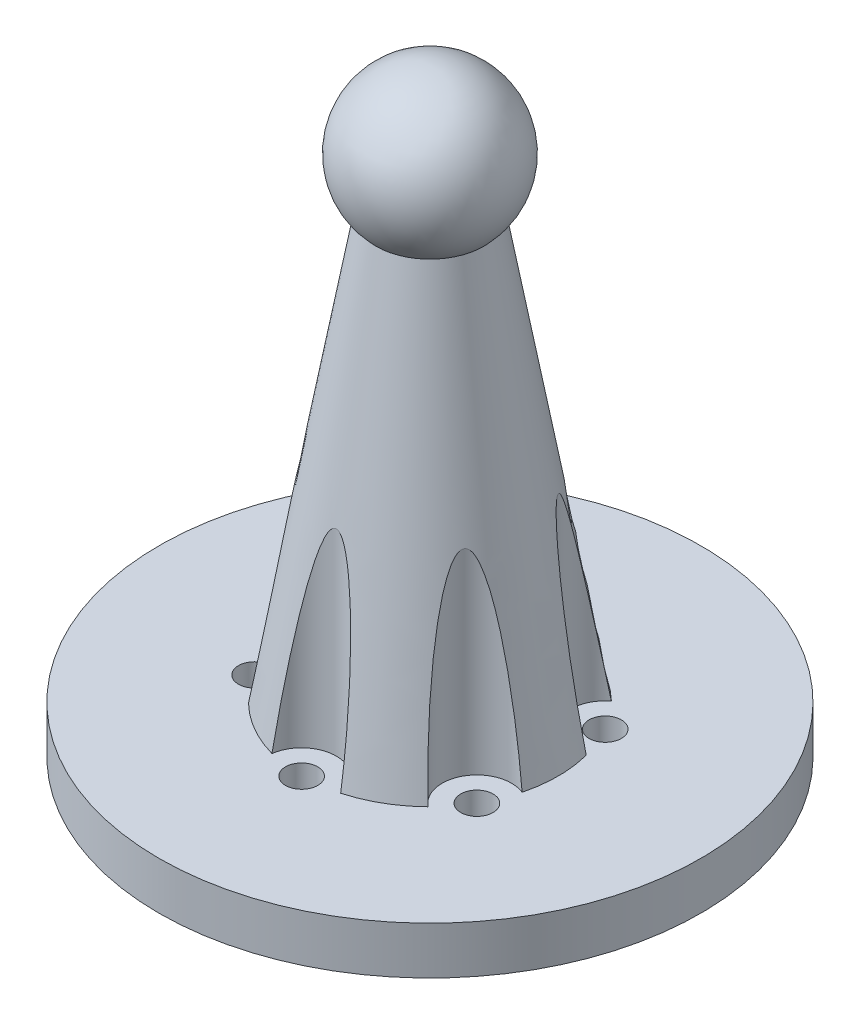
from build123d import *

# Parameters (mm, degrees)
SKETCH_1_R          = 28.5
SKETCH_1_R_2        = 1.7
EXTRUDE_1_DEPTH     = 5
SKETCH_2_R          = 13.5
EXTRUDE_2_DEPTH     = 50
EXTRUDE_2_TAPER     = 10
SKETCH_3_R          = 3.65
CUT_EXTRUDE_1_DEPTH = 50


with BuildPart() as part:
    # 草图1 → 凸台-拉伸1 (new body)
    with BuildSketch(Plane(origin=(0, 0, 0), x_dir=(1, 0, 0), z_dir=(0, 1, 0))):
        Circle(SKETCH_1_R)
        with Locations((0, 13.5)):
            Circle(SKETCH_1_R_2, mode=Mode.SUBTRACT)
        with Locations((11.691342951, 6.75)):
            Circle(SKETCH_1_R_2, mode=Mode.SUBTRACT)
        with Locations((11.691342951, -6.75)):
            Circle(SKETCH_1_R_2, mode=Mode.SUBTRACT)
        with Locations((0, -13.5)):
            Circle(SKETCH_1_R_2, mode=Mode.SUBTRACT)
        with Locations((-11.691342951, -6.75)):
            Circle(SKETCH_1_R_2, mode=Mode.SUBTRACT)
        with Locations((-11.691342951, 6.75)):
            Circle(SKETCH_1_R_2, mode=Mode.SUBTRACT)
    extrude(amount=EXTRUDE_1_DEPTH)

    # 草图2 → 凸台-拉伸2 (add)
    with BuildSketch(Plane(origin=(0, 5, 0), x_dir=(1, 0, 0), z_dir=(0, 1, 0))):
        Circle(SKETCH_2_R)
    extrude(amount=EXTRUDE_2_DEPTH, taper=EXTRUDE_2_TAPER)

    # 草图3 → 切除-拉伸1 (cut)
    with BuildSketch(Plane.XZ.offset(-5)):
        with Locations((-11.691342951, -6.75)):
            Circle(SKETCH_3_R)
        with Locations((-11.691342951, 6.75)):
            Circle(SKETCH_3_R)
        with Locations((0, 13.5)):
            Circle(SKETCH_3_R)
        with Locations((11.691342951, 6.75)):
            Circle(SKETCH_3_R)
        with Locations((11.691342951, -6.75)):
            Circle(SKETCH_3_R)
        with Locations((0, -13.5)):
            Circle(SKETCH_3_R)
    extrude(amount=-CUT_EXTRUDE_1_DEPTH, mode=Mode.SUBTRACT)

    # 草图4 → 旋转5 (revolve)
    with BuildSketch(Plane(origin=(0, 55, 0), x_dir=(1, 0, 0), z_dir=(0, 1, 0))):
        with BuildLine():
            Line((0, 8), (0, -8))
            ThreePointArc((0, -8), (8, 0), (0, 8))
        make_face()
    revolve(axis=Axis((0, 55, -8), (0, 0, 1)))


solid = part.part
